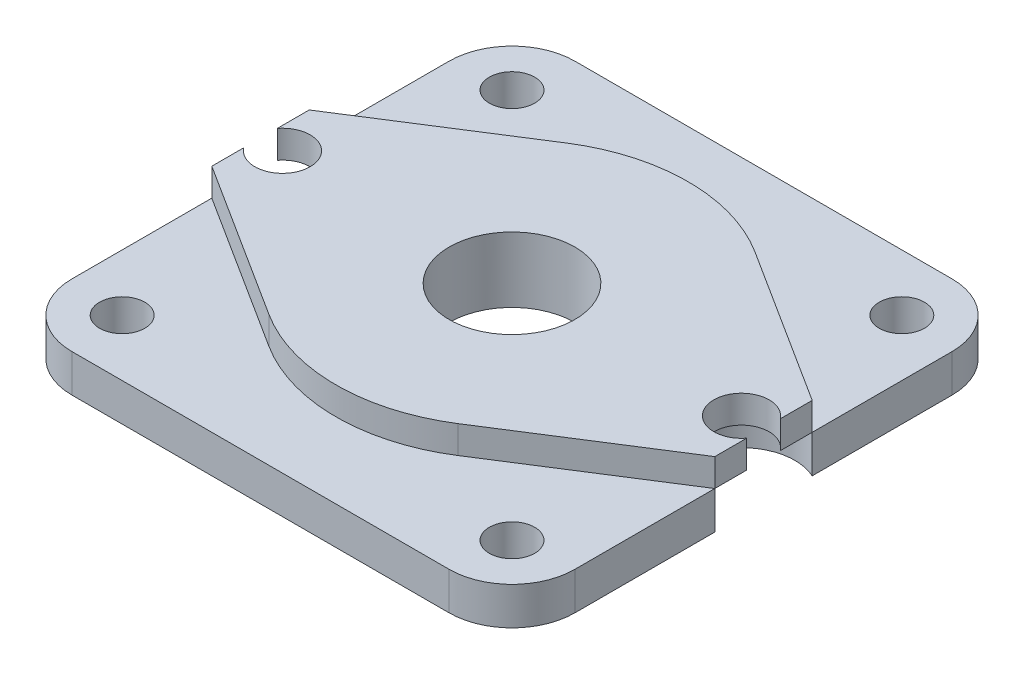
from build123d import *

# Parameters (mm, degrees)
SKETCH_1_R          = 1.8
SKETCH_1_R_2        = 5
EXTRUDE_1_DEPTH     = 3
EXTRUDE_2_DEPTH     = 2.2
SKETCH_3_R          = 5
CUT_EXTRUDE_1_DEPTH = 2.2


with BuildPart() as part:
    # 草图1 → 凸台-拉伸1 (new body)
    with BuildSketch(Plane(origin=(0, 0, 0), x_dir=(1, 0, 0), z_dir=(0, 1, 0))):
        with BuildLine():
            Line((20, -3.872983346), (20, -15))
            ThreePointArc((20, -15), (18.535533906, -18.535533906), (15, -20))
            Line((15, -20), (-15, -20))
            ThreePointArc((-15, -20), (-18.535533906, -18.535533906), (-20, -15))
            Line((-20, -15), (-20, -3.872983346))
            ThreePointArc((-20, -3.872983346), (-14, 0), (-20, 3.872983346))
            Line((-20, 3.872983346), (-20, 15))
            ThreePointArc((-20, 15), (-18.535533906, 18.535533906), (-15, 20))
            Line((-15, 20), (15, 20))
            ThreePointArc((15, 20), (18.535533906, 18.535533906), (20, 15))
            Line((20, 15), (20, 3.872983346))
            ThreePointArc((20, 3.872983346), (14, 0), (20, -3.872983346))
        make_face()
        with Locations((-15.5, 15.5)):
            Circle(SKETCH_1_R, mode=Mode.SUBTRACT)
        with Locations((15.5, 15.5)):
            Circle(SKETCH_1_R, mode=Mode.SUBTRACT)
        with Locations((-15.5, -15.5)):
            Circle(SKETCH_1_R, mode=Mode.SUBTRACT)
        with Locations((15.5, -15.5)):
            Circle(SKETCH_1_R, mode=Mode.SUBTRACT)
        Circle(SKETCH_1_R_2, mode=Mode.SUBTRACT)
    extrude(amount=EXTRUDE_1_DEPTH)

    # 草图2 → 凸台-拉伸2 (add)
    with BuildSketch(Plane(origin=(0, 3, 0), x_dir=(1, 0, 0), z_dir=(0, 1, 0))):
        with BuildLine():
            Line((-20, 3.872983346), (-7.512267775, 11.81379841))
            ThreePointArc((-7.512267775, 11.81379841), (0, 14), (7.512267775, 11.81379841))
            Line((7.512267775, 11.81379841), (20, 3.872983346))
            Line((20, 3.872983346), (20, 1.333229163))
            ThreePointArc((20, 1.333229163), (16.05, 0), (20, -1.333229163))
            Line((20, -1.333229163), (20, -3.872983346))
            Line((20, -3.872983346), (7.512267775, -11.81379841))
            ThreePointArc((7.512267775, -11.81379841), (0, -14), (-7.512267775, -11.81379841))
            Line((-7.512267775, -11.81379841), (-20, -3.872983346))
            Line((-20, -3.872983346), (-20, -1.333229163))
            ThreePointArc((-20, -1.333229163), (-16.05, 0), (-20, 1.333229163))
            Line((-20, 1.333229163), (-20, 3.872983346))
        make_face()
    extrude(amount=EXTRUDE_2_DEPTH)

    # 草图3 → 切除-拉伸1 (cut)
    with BuildSketch(Plane.XZ.offset(-3)):
        Circle(SKETCH_3_R)
    extrude(amount=-CUT_EXTRUDE_1_DEPTH, mode=Mode.SUBTRACT)


solid = part.part
